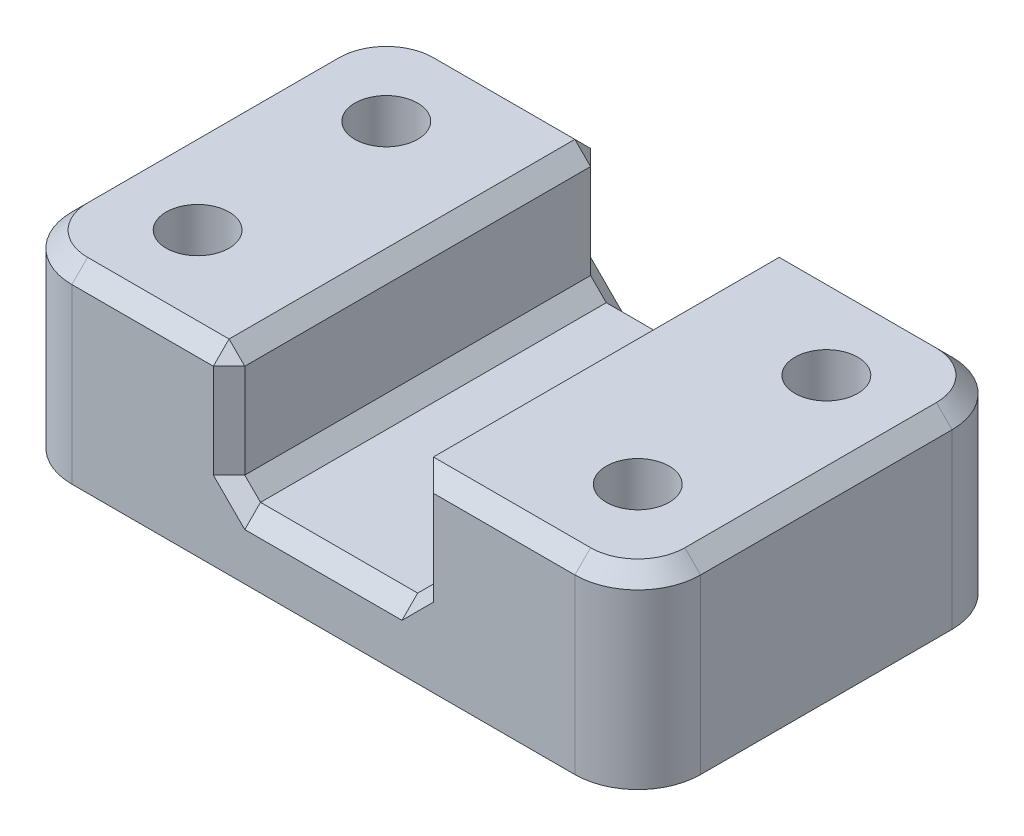
from build123d import *

# Parameters (mm, degrees)
SKETCH2_W           = 127
SKETCH2_H           = 76.2
SKETCH2_R           = 6.35
BOSS_EXTRUDE1_DEPTH = 38.1
SKETCH3_W           = 38.1
SKETCH3_H           = 76.2
CUT_EXTRUDE2_DEPTH  = 25.4
FILLET1_R           = 12.7
CHAMFER1_SIZE       = 3.175


with BuildPart() as part:
    # Sketch2 → Boss-Extrude1 (new body)
    with BuildSketch(Plane(origin=(0, 0, 0), x_dir=(1, 0, 0), z_dir=(0, 1, 0))):
        Rectangle(SKETCH2_W, SKETCH2_H)
        with Locations((-44.45, 19.05)):
            Circle(SKETCH2_R, mode=Mode.SUBTRACT)
        with Locations((44.45, 19.05)):
            Circle(SKETCH2_R, mode=Mode.SUBTRACT)
        with Locations((-44.45, -19.05)):
            Circle(SKETCH2_R, mode=Mode.SUBTRACT)
        with Locations((44.45, -19.05)):
            Circle(SKETCH2_R, mode=Mode.SUBTRACT)
    extrude(amount=BOSS_EXTRUDE1_DEPTH)

    # Sketch3 → Cut-Extrude2 (cut)
    with BuildSketch(Plane(origin=(0, 38.1, 0), x_dir=(1, 0, 0), z_dir=(0, 1, 0))):
        Rectangle(SKETCH3_W, SKETCH3_H)
    extrude(amount=-CUT_EXTRUDE2_DEPTH, mode=Mode.SUBTRACT)

    # Fillet1
    fillet1_edges = [part.edges().sort_by_distance(p)[0] for p in [
        (63.5, 19.05, 38.1),
        (-63.5, 19.05, 38.1),
        (-63.5, 19.05, -38.1),
        (63.5, 19.05, -38.1),
    ]]
    fillet(fillet1_edges, radius=FILLET1_R)

    # Chamfer1
    chamfer1_edges = [part.edges().sort_by_distance(p)[0] for p in [
        (34.925, 38.1, 38.1),
        (-34.925, 38.1, -38.1),
        (-19.05, 25.4, -38.1),
        (19.05, 12.7, 0),
        (19.05, 25.4, -38.1),
        (0, 12.7, 38.1),
        (19.05, 25.4, 38.1),
        (-19.05, 38.1, 0),
        (-19.05, 25.4, 38.1),
        (0, 12.7, -38.1),
        (-19.05, 12.7, 0),
        (-63.5, 38.1, 0),
        (34.925, 38.1, -38.1),
        (-34.925, 38.1, 38.1),
        (-59.780256121, 38.1, 34.380256121),
        (-59.780256121, 38.1, -34.380256121),
        (63.5, 38.1, 0),
        (59.780256121, 38.1, 34.380256121),
        (59.780256121, 38.1, -34.380256121),
    ]]
    chamfer(chamfer1_edges, length=CHAMFER1_SIZE)


solid = part.part
